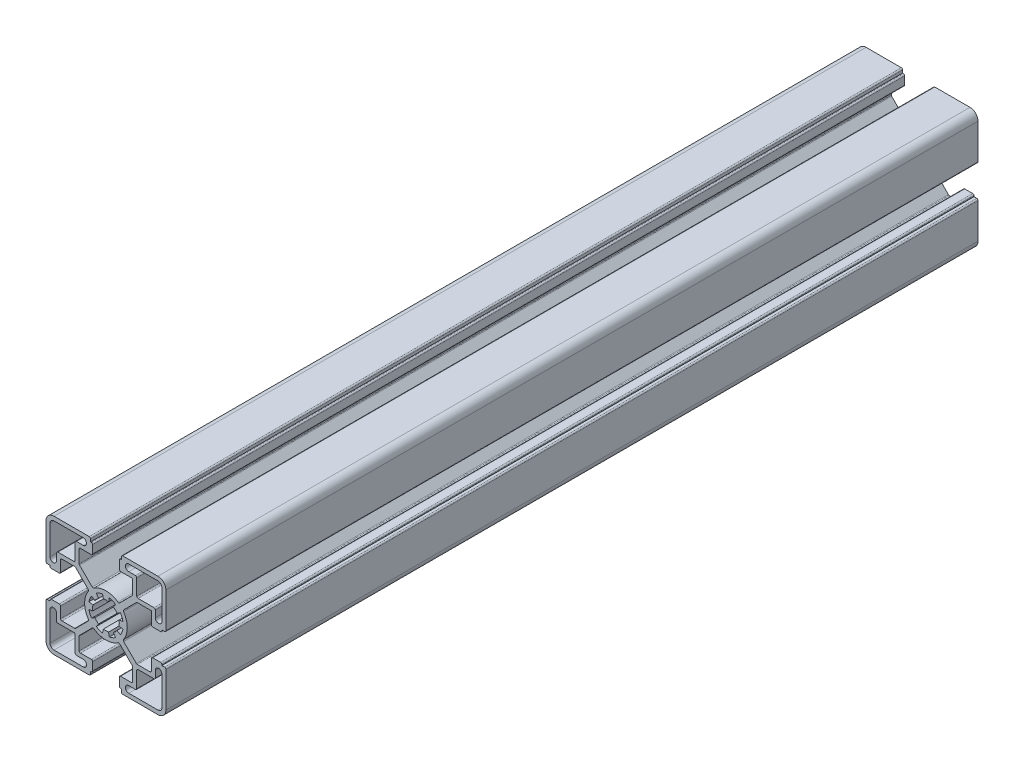
from build123d import *

# Parameters (mm, degrees)
SKETCH3_R                = 5
BOSS_EXTRUDE1_DEPTH      = 152.4
BOSS_EXTRUDE1_DEPTH_BACK = 152.4
FILLET1_R                = 0.5
CUT_EXTRUDE1_DEPTH       = 305.8


with BuildPart() as part:
    # Sketch3 → Boss-Extrude1 (new body, two sides)
    with BuildSketch(Plane.XY) as boss_extrude1_sk:
        with BuildLine():
            Line((-11.55, -10.05), (-6.356915373, -4.856915373))
            ThreePointArc((-6.356915373, -4.856915373), (-8, 0), (-6.356915373, 4.856915373))
            Line((-6.356915373, 4.856915373), (-11.55, 10.05))
            Line((-11.55, 10.05), (-17.025, 10.05))
            Line((-17.025, 10.05), (-17.025, 5))
            Line((-17.025, 5), (-21, 5))
            Line((-21, 5), (-21, 5.8))
            Line((-21, 5.8), (-22.5, 5.8))
            Line((-22.5, 5.8), (-22.5, 19.5))
            ThreePointArc((-22.5, 19.5), (-21.621320344, 21.621320344), (-19.5, 22.5))
            Line((-19.5, 22.5), (-5.8, 22.5))
            Line((-5.8, 22.5), (-5.8, 21))
            Line((-5.8, 21), (-5, 21))
            Line((-5, 21), (-5, 17.025))
            Line((-5, 17.025), (-10.05, 17.025))
            Line((-10.05, 17.025), (-10.05, 11.55))
            Line((-10.05, 11.55), (-4.856915373, 6.356915373))
            ThreePointArc((-4.856915373, 6.356915373), (0, 8), (4.856915373, 6.356915373))
            Line((4.856915373, 6.356915373), (10.05, 11.55))
            Line((10.05, 11.55), (10.05, 17.025))
            Line((10.05, 17.025), (5, 17.025))
            Line((5, 17.025), (5, 21))
            Line((5, 21), (5.8, 21))
            Line((5.8, 21), (5.8, 22.5))
            Line((5.8, 22.5), (19.5, 22.5))
            ThreePointArc((19.5, 22.5), (21.621320344, 21.621320344), (22.5, 19.5))
            Line((22.5, 19.5), (22.5, 5.8))
            Line((22.5, 5.8), (21, 5.8))
            Line((21, 5.8), (21, 5))
            Line((21, 5), (17.025, 5))
            Line((17.025, 5), (17.025, 10.05))
            Line((17.025, 10.05), (11.55, 10.05))
            Line((11.55, 10.05), (6.356915373, 4.856915373))
            ThreePointArc((6.356915373, 4.856915373), (8, 0), (6.356915373, -4.856915373))
            Line((6.356915373, -4.856915373), (11.55, -10.05))
            Line((11.55, -10.05), (17.025, -10.05))
            Line((17.025, -10.05), (17.025, -5))
            Line((17.025, -5), (21, -5))
            Line((21, -5), (21, -5.8))
            Line((21, -5.8), (22.5, -5.8))
            Line((22.5, -5.8), (22.5, -19.5))
            ThreePointArc((22.5, -19.5), (21.621320344, -21.621320344), (19.5, -22.5))
            Line((19.5, -22.5), (5.8, -22.5))
            Line((5.8, -22.5), (5.8, -21))
            Line((5.8, -21), (5, -21))
            Line((5, -21), (5, -17.025))
            Line((5, -17.025), (10.05, -17.025))
            Line((10.05, -17.025), (10.05, -11.55))
            Line((10.05, -11.55), (4.856915373, -6.356915373))
            ThreePointArc((4.856915373, -6.356915373), (0, -8), (-4.856915373, -6.356915373))
            Line((-4.856915373, -6.356915373), (-10.05, -11.55))
            Line((-10.05, -11.55), (-10.05, -17.025))
            Line((-10.05, -17.025), (-5, -17.025))
            Line((-5, -17.025), (-5, -21))
            Line((-5, -21), (-5.8, -21))
            Line((-5.8, -21), (-5.8, -22.5))
            Line((-5.8, -22.5), (-19.5, -22.5))
            ThreePointArc((-19.5, -22.5), (-21.621320344, -21.621320344), (-22.5, -19.5))
            Line((-22.5, -19.5), (-22.5, -5.8))
            Line((-22.5, -5.8), (-21, -5.8))
            Line((-21, -5.8), (-21, -5))
            Line((-21, -5), (-17.025, -5))
            Line((-17.025, -5), (-17.025, -10.05))
            Line((-17.025, -10.05), (-11.55, -10.05))
        make_face()
        Circle(SKETCH3_R, mode=Mode.SUBTRACT)
        with BuildLine():
            Line((-21, 8.5375), (-21, 19.5))
            ThreePointArc((-21, 19.5), (-20.560660172, 20.560660172), (-19.5, 21))
            Line((-19.5, 21), (-8.5375, 21))
            ThreePointArc((-8.5375, 21), (-7.3, 19.7625), (-8.5375, 18.525))
            Line((-8.5375, 18.525), (-11.55, 18.525))
            Line((-11.55, 18.525), (-11.55, 11.55))
            Line((-11.55, 11.55), (-18.525, 11.55))
            Line((-18.525, 11.55), (-18.525, 8.5375))
            ThreePointArc((-18.525, 8.5375), (-19.7625, 7.3), (-21, 8.5375))
        make_face(mode=Mode.SUBTRACT)
        with BuildLine():
            Line((8.5375, 21), (19.5, 21))
            ThreePointArc((19.5, 21), (20.560660172, 20.560660172), (21, 19.5))
            Line((21, 19.5), (21, 8.5375))
            ThreePointArc((21, 8.5375), (19.7625, 7.3), (18.525, 8.5375))
            Line((18.525, 8.5375), (18.525, 11.55))
            Line((18.525, 11.55), (11.55, 11.55))
            Line((11.55, 11.55), (11.55, 18.525))
            Line((11.55, 18.525), (8.5375, 18.525))
            ThreePointArc((8.5375, 18.525), (7.3, 19.7625), (8.5375, 21))
        make_face(mode=Mode.SUBTRACT)
        with BuildLine():
            Line((21, -8.5375), (21, -19.5))
            ThreePointArc((21, -19.5), (20.560660172, -20.560660172), (19.5, -21))
            Line((19.5, -21), (8.5375, -21))
            ThreePointArc((8.5375, -21), (7.3, -19.7625), (8.5375, -18.525))
            Line((8.5375, -18.525), (11.55, -18.525))
            Line((11.55, -18.525), (11.55, -11.55))
            Line((11.55, -11.55), (18.525, -11.55))
            Line((18.525, -11.55), (18.525, -8.5375))
            ThreePointArc((18.525, -8.5375), (19.7625, -7.3), (21, -8.5375))
        make_face(mode=Mode.SUBTRACT)
        with BuildLine():
            Line((-8.5375, -21), (-19.5, -21))
            ThreePointArc((-19.5, -21), (-20.560660172, -20.560660172), (-21, -19.5))
            Line((-21, -19.5), (-21, -8.5375))
            ThreePointArc((-21, -8.5375), (-19.7625, -7.3), (-18.525, -8.5375))
            Line((-18.525, -8.5375), (-18.525, -11.55))
            Line((-18.525, -11.55), (-11.55, -11.55))
            Line((-11.55, -11.55), (-11.55, -18.525))
            Line((-11.55, -18.525), (-8.5375, -18.525))
            ThreePointArc((-8.5375, -18.525), (-7.3, -19.7625), (-8.5375, -21))
        make_face(mode=Mode.SUBTRACT)
    extrude(amount=BOSS_EXTRUDE1_DEPTH)
    extrude(boss_extrude1_sk.sketch, amount=-BOSS_EXTRUDE1_DEPTH_BACK)

    # Fillet1
    fillet1_edges = [part.edges().sort_by_distance(p)[0] for p in [
        (-11.55, -18.525, 0),
        (-11.55, -11.55, 0),
        (18.525, -11.55, 0),
        (11.55, -11.55, 0),
        (11.55, -18.525, 0),
        (11.55, 18.525, 0),
        (11.55, 11.55, 0),
        (18.525, 11.55, 0),
        (-18.525, 11.55, 0),
        (-11.55, 11.55, 0),
        (-11.55, 18.525, 0),
        (6.356915373, -4.856915373, 0),
        (11.55, -10.05, 0),
        (17.025, -10.05, 0),
        (17.025, -5, 0),
        (21, -5, 0),
        (22.5, -5.8, 0),
        (5.8, -22.5, 0),
        (5, -21, 0),
        (5, -17.025, 0),
        (10.05, -17.025, 0),
        (10.05, -11.55, 0),
        (4.856915373, -6.356915373, 0),
        (-4.856915373, -6.356915373, 0),
        (-10.05, -11.55, 0),
        (-10.05, -17.025, 0),
        (-5, -17.025, 0),
        (-5, -21, 0),
        (-5.8, -22.5, 0),
        (-22.5, -5.8, 0),
        (-21, -5, 0),
        (-17.025, -5, 0),
        (-17.025, -10.05, 0),
        (-11.55, -10.05, 0),
        (-6.356915373, -4.856915373, 0),
        (-6.356915373, 4.856915373, 0),
        (-11.55, 10.05, 0),
        (-17.025, 10.05, 0),
        (-17.025, 5, 0),
        (-21, 5, 0),
        (-22.5, 5.8, 0),
        (-5.8, 22.5, 0),
        (-5, 21, 0),
        (-5, 17.025, 0),
        (-10.05, 17.025, 0),
        (-10.05, 11.55, 0),
        (-4.856915373, 6.356915373, 0),
        (4.856915373, 6.356915373, 0),
        (10.05, 11.55, 0),
        (10.05, 17.025, 0),
        (5, 17.025, 0),
        (5, 21, 0),
        (5.8, 22.5, 0),
        (22.5, 5.8, 0),
        (21, 5, 0),
        (17.025, 5, 0),
        (11.55, 10.05, 0),
        (6.356915373, 4.856915373, 0),
    ]]
    fillet(fillet1_edges, radius=FILLET1_R)

    # Sketch4 → Cut-Extrude1 (cut, through all)
    with BuildSketch(Plane.XY.offset(152.4)):
        with BuildLine():
            Line((-1.268087093, 6.375104323), (-0.97545161, 4.903926402))
            ThreePointArc((-0.97545161, 4.903926402), (-1.913417162, 4.619397663), (-2.777851165, 4.157348062))
            Line((-2.777851165, 4.157348062), (-3.611206515, 5.40455248))
            ThreePointArc((-3.611206515, 5.40455248), (-2.48744231, 6.005216961), (-1.268087093, 6.375104323))
        make_face()
        with BuildLine():
            Line((1.268087093, 6.375104323), (0.97545161, 4.903926402))
            ThreePointArc((0.97545161, 4.903926402), (1.913417162, 4.619397663), (2.777851165, 4.157348062))
            Line((2.777851165, 4.157348062), (3.611206515, 5.40455248))
            ThreePointArc((3.611206515, 5.40455248), (2.48744231, 6.005216961), (1.268087093, 6.375104323))
        make_face()
        with BuildLine():
            Line((5.40455248, 3.611206515), (4.157348062, 2.777851165))
            ThreePointArc((4.157348062, 2.777851165), (4.619397663, 1.913417162), (4.903926402, 0.97545161))
            Line((4.903926402, 0.97545161), (6.375104323, 1.268087093))
            ThreePointArc((6.375104323, 1.268087093), (6.005216961, 2.48744231), (5.40455248, 3.611206515))
        make_face()
        with BuildLine():
            Line((6.375104323, -1.268087093), (4.903926402, -0.97545161))
            ThreePointArc((4.903926402, -0.97545161), (4.619397663, -1.913417162), (4.157348062, -2.777851165))
            Line((4.157348062, -2.777851165), (5.40455248, -3.611206515))
            ThreePointArc((5.40455248, -3.611206515), (6.005216961, -2.48744231), (6.375104323, -1.268087093))
        make_face()
        with BuildLine():
            Line((3.611206515, -5.40455248), (2.777851165, -4.157348062))
            ThreePointArc((2.777851165, -4.157348062), (1.913417162, -4.619397663), (0.97545161, -4.903926402))
            Line((0.97545161, -4.903926402), (1.268087093, -6.375104323))
            ThreePointArc((1.268087093, -6.375104323), (2.48744231, -6.005216961), (3.611206515, -5.40455248))
        make_face()
        with BuildLine():
            Line((-1.268087093, -6.375104323), (-0.97545161, -4.903926402))
            ThreePointArc((-0.97545161, -4.903926402), (-1.913417162, -4.619397663), (-2.777851165, -4.157348062))
            Line((-2.777851165, -4.157348062), (-3.611206515, -5.40455248))
            ThreePointArc((-3.611206515, -5.40455248), (-2.48744231, -6.005216961), (-1.268087093, -6.375104323))
        make_face()
        with BuildLine():
            Line((-5.40455248, -3.611206515), (-4.157348062, -2.777851165))
            ThreePointArc((-4.157348062, -2.777851165), (-4.619397663, -1.913417162), (-4.903926402, -0.97545161))
            Line((-4.903926402, -0.97545161), (-6.375104323, -1.268087093))
            ThreePointArc((-6.375104323, -1.268087093), (-6.005216961, -2.48744231), (-5.40455248, -3.611206515))
        make_face()
        with BuildLine():
            Line((-6.375104323, 1.268087093), (-4.903926402, 0.97545161))
            ThreePointArc((-4.903926402, 0.97545161), (-4.619397663, 1.913417162), (-4.157348062, 2.777851165))
            Line((-4.157348062, 2.777851165), (-5.40455248, 3.611206515))
            ThreePointArc((-5.40455248, 3.611206515), (-6.005216961, 2.48744231), (-6.375104323, 1.268087093))
        make_face()
    extrude(amount=-CUT_EXTRUDE1_DEPTH, mode=Mode.SUBTRACT)


solid = part.part
